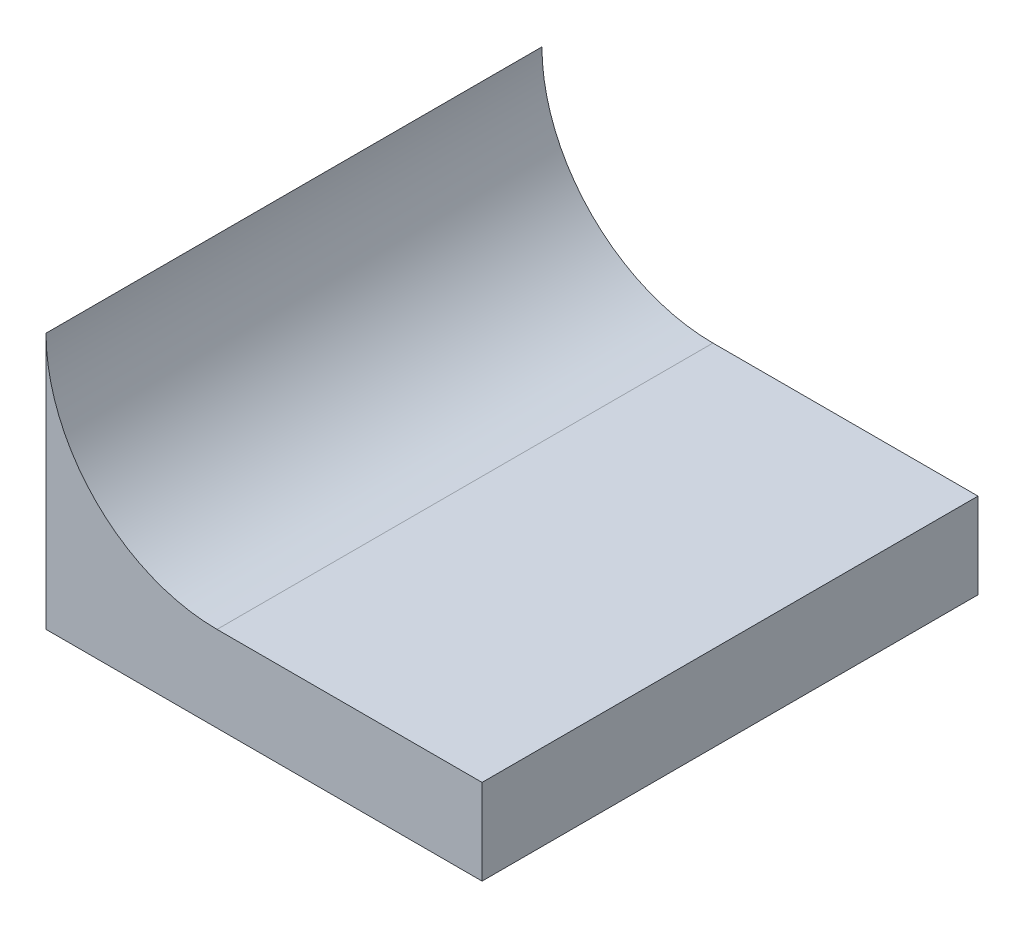
from build123d import *

# Parameters (mm, degrees)
BOSS_EXTRUDE1_DEPTH = 0.29


with BuildPart() as part:
    # Sketch1 → Boss-Extrude1 (new body, symmetric)
    with BuildSketch(Plane.XY):
        with BuildLine():
            Line((0, 0), (0.51, 0))
            Line((0.51, 0), (0.51, 0.1))
            Line((0.51, 0.1), (0.2, 0.1))
            ThreePointArc((0.2, 0.1), (0.058578644, 0.158578644), (0, 0.3))
            Line((0, 0.3), (0, 0))
        make_face()
    extrude(amount=BOSS_EXTRUDE1_DEPTH, both=True)


solid = part.part
